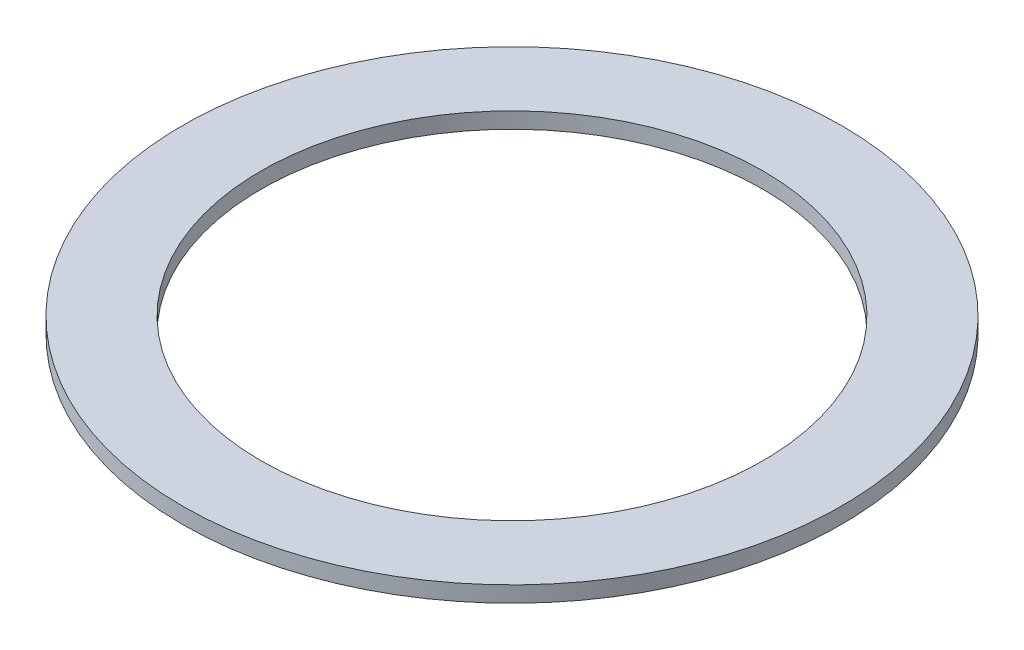
from build123d import *

# Parameters (mm, degrees)
SKETCH1_R           = 7.8867
SKETCH1_R_2         = 6.0071
BOSS_EXTRUDE1_DEPTH = 0.381


with BuildPart() as part:
    # Sketch1 → Boss-Extrude1 (new body)
    with BuildSketch(Plane(origin=(0, 0, 0), x_dir=(1, 0, 0), z_dir=(0, 1, 0))):
        Circle(SKETCH1_R)
        Circle(SKETCH1_R_2, mode=Mode.SUBTRACT)
    extrude(amount=BOSS_EXTRUDE1_DEPTH)


solid = part.part
